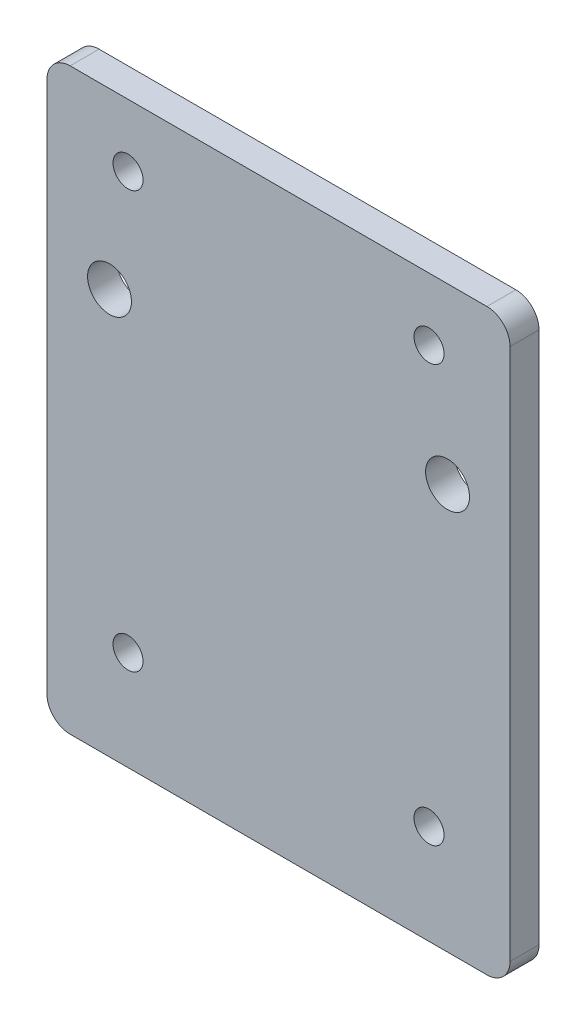
from build123d import *

# Parameters (mm, degrees)
SKETCH1_W                        = 50.8
SKETCH1_H                        = 63.5
BOSS_EXTRUDE1_DEPTH              = 3.175
F_10_0_1935_DIAMETER_HOLE1_D     = 4.8133
F_10_0_1935_DIAMETER_HOLE1_DEPTH = 3.175
M3_CLEARANCE_HOLE1_D             = 3.2984
M3_CLEARANCE_HOLE1_DEPTH         = 3.175
FILLET1_R                        = 2.54


with BuildPart() as part:
    # Sketch1 → Boss-Extrude1 (new body)
    with BuildSketch(Plane.XY):
        Rectangle(SKETCH1_W, SKETCH1_H)
    extrude(amount=BOSS_EXTRUDE1_DEPTH)

    # #10 (0.1935) Diameter Hole1
    with Locations(Plane(origin=(0, 0, 0), x_dir=(-1, 0, 0), z_dir=(0, 0, -1))):
        with Locations((-18.542, 12.7), (18.542, 12.7)):
            Hole(F_10_0_1935_DIAMETER_HOLE1_D / 2, depth=F_10_0_1935_DIAMETER_HOLE1_DEPTH)

    # M3 Clearance Hole1
    with Locations(Plane(origin=(0, 0, 0), x_dir=(-1, 0, 0), z_dir=(0, 0, -1))):
        with Locations((-16.51, 24.892), (16.51, 24.892), (-16.51, -20.828), (16.51, -20.828)):
            Hole(M3_CLEARANCE_HOLE1_D / 2, depth=M3_CLEARANCE_HOLE1_DEPTH)

    # Fillet1
    fillet1_edges = [part.edges().sort_by_distance(p)[0] for p in [
        (25.4, -31.75, 1.5875),
        (-25.4, -31.75, 1.5875),
        (-25.4, 31.75, 1.5875),
        (25.4, 31.75, 1.5875),
    ]]
    fillet(fillet1_edges, radius=FILLET1_R)


solid = part.part
